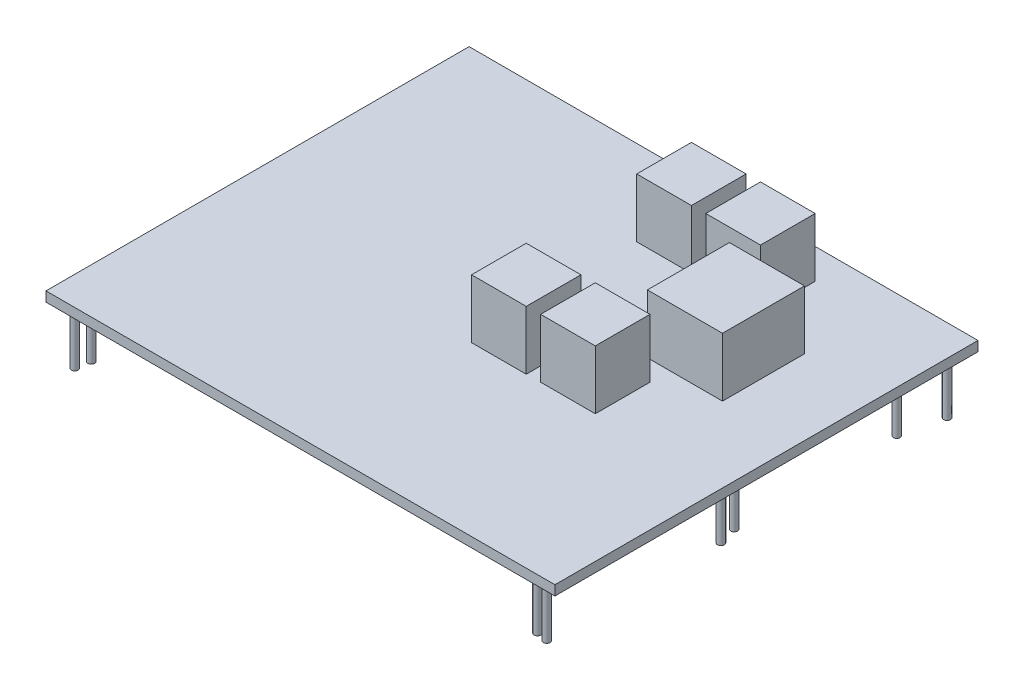
from build123d import *

# Parameters (mm, degrees)
SKETCH2_W           = 259.71
SKETCH2_H           = 215.9
BOSS_EXTRUDE1_DEPTH = 5
SKETCH1_R           = 1.75
BOSS_EXTRUDE2_DEPTH = 30
FANS_W              = 27.900833557
FANS_H              = 27.900833558
FANS_W_2            = 38.326934518
FANS_H_2            = 41.851250335
FANS_H_3            = 27.900833557
BOSS_EXTRUDE3_DEPTH = 30


with BuildPart() as part:
    # Sketch2 → Boss-Extrude1 (new body)
    with BuildSketch(Plane(origin=(0, 0, 0), x_dir=(1, 0, 0), z_dir=(0, 1, 0))):
        with Locations((-196.717193813, 0.240534117)):
            Rectangle(SKETCH2_W, SKETCH2_H)
    extrude(amount=BOSS_EXTRUDE1_DEPTH)

    # Sketch1 → Boss-Extrude2 (add)
    with BuildSketch(Plane(origin=(0, 0, 0), x_dir=(1, 0, 0), z_dir=(0, 1, 0))):
        with Locations((-320.092193813, 101.170534117)):
            Circle(SKETCH1_R)
        with Locations((-312.852193813, 99.850534117)):
            Circle(SKETCH1_R)
        with Locations((-318.832193813, -92.309465883)):
            Circle(SKETCH1_R)
        with Locations((-320.102193813, -99.489465883)):
            Circle(SKETCH1_R)
        with Locations((-177.862193813, -34.399465883)):
            Circle(SKETCH1_R)
        with Locations((-170.242193813, -34.399465883)):
            Circle(SKETCH1_R)
        with Locations((-104.382193813, -25.149465883)):
            Circle(SKETCH1_R)
        with Locations((-216.142193813, -6.769465883)):
            Circle(SKETCH1_R)
        with Locations((-77.992193813, -11.859465883)):
            Circle(SKETCH1_R)
        with Locations((-80.702193813, -2.389465883)):
            Circle(SKETCH1_R)
        with Locations((-84.902193813, -98.529465883)):
            Circle(SKETCH1_R)
        with Locations((-79.259756914, -99.489465883)):
            Circle(SKETCH1_R)
        with Locations((-104.372193813, 71.880534117)):
            Circle(SKETCH1_R)
        with Locations((-80.542193813, 80.410534117)):
            Circle(SKETCH1_R)
        with Locations((-75.622193813, 101.170534117)):
            Circle(SKETCH1_R)
        with Locations((-224.842193813, 89.780534117)):
            Circle(SKETCH1_R)
    extrude(amount=-BOSS_EXTRUDE2_DEPTH)

    # fans → Boss-Extrude3 (add)
    with BuildSketch(Plane(origin=(0, 5, 0), x_dir=(1, 0, 0), z_dir=(0, 1, 0))):
        with Locations((-146.055153933, -7.909446212)):
            Rectangle(FANS_W, FANS_H)
        with Locations((-124.395296303, 37.09900371)):
            Rectangle(FANS_W_2, FANS_H_2)
        with Locations((-181.151465618, -8.056292705)):
            Rectangle(FANS_W, FANS_H_3)
        with Locations((-148.478121058, 78.803407554)):
            Rectangle(FANS_W, FANS_H_3)
        with Locations((-183.574432743, 78.656561061)):
            Rectangle(FANS_W, FANS_H_3)
    extrude(amount=BOSS_EXTRUDE3_DEPTH)


solid = part.part
